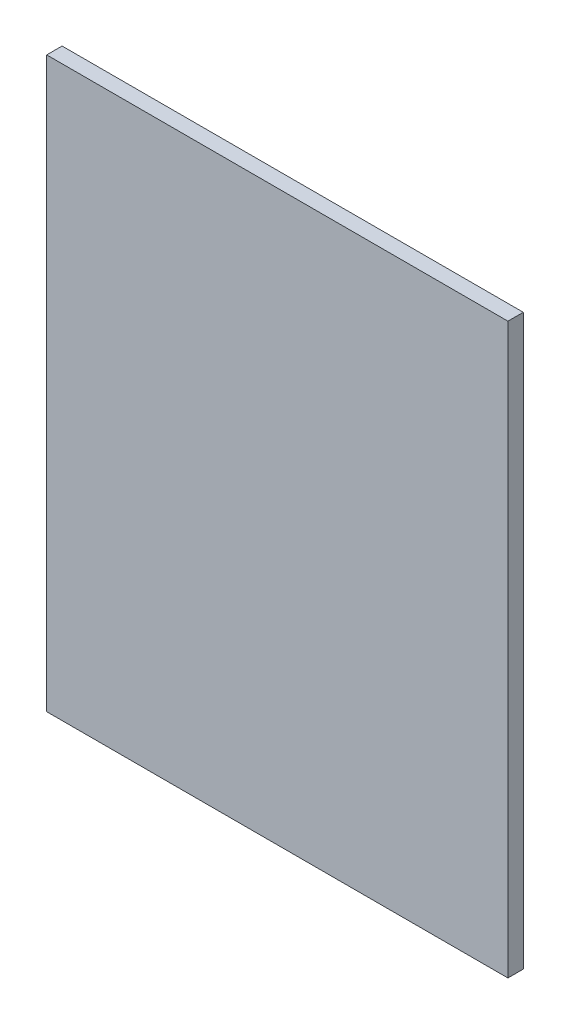
from build123d import *

# Parameters (mm, degrees)
SKETCH_1_W      = 300
SKETCH_1_H      = 370
EXTRUDE_1_DEPTH = 10


with BuildPart() as part:
    # 草图1 → 凸台-拉伸1 (new body)
    with BuildSketch(Plane.XY):
        with Locations((101.553848331, -151.460356537)):
            Rectangle(SKETCH_1_W, SKETCH_1_H)
    extrude(amount=EXTRUDE_1_DEPTH)


solid = part.part
